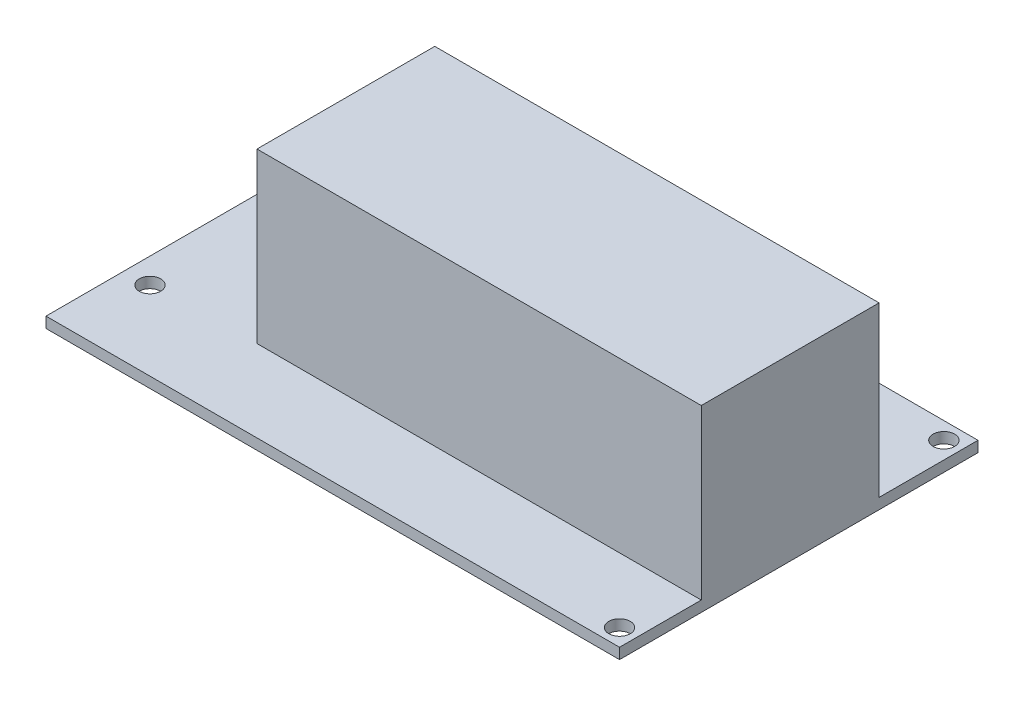
from build123d import *

# Parameters (mm, degrees)
SKETCH2_R           = 1.5
BOSS_EXTRUDE1_DEPTH = 1.5
SKETCH2_3_W         = 61.970625282
SKETCH2_3_H         = 24.8
BOSS_EXTRUDE2_DEPTH = 25


with BuildPart() as part:
    # Sketch2 → Boss-Extrude1 (new body)
    with BuildSketch(Plane(origin=(0, 0, 0), x_dir=(1, 0, 0), z_dir=(0, 1, 0))):
        Polygon((80, 0), (0, 0), (0, -50), (80, -50), (80, -38.6), (18.029374718, -38.6), (18.029374718, -13.8), (80, -13.8), align=None)
        with Locations((3.5, -39)):
            Circle(SKETCH2_R, mode=Mode.SUBTRACT)
        with Locations((77.62, -47.62)):
            Circle(SKETCH2_R, mode=Mode.SUBTRACT)
        with Locations((3.5, -11)):
            Circle(SKETCH2_R, mode=Mode.SUBTRACT)
        with Locations((77.62, -2.38)):
            Circle(SKETCH2_R, mode=Mode.SUBTRACT)
    extrude(amount=BOSS_EXTRUDE1_DEPTH)

    # Sketch2_3 → Boss-Extrude2 (add)
    with BuildSketch(Plane(origin=(0, 0, 0), x_dir=(1, 0, 0), z_dir=(0, 1, 0))):
        with Locations((49.014687359, -26.2)):
            Rectangle(SKETCH2_3_W, SKETCH2_3_H)
    extrude(amount=BOSS_EXTRUDE2_DEPTH)


solid = part.part
